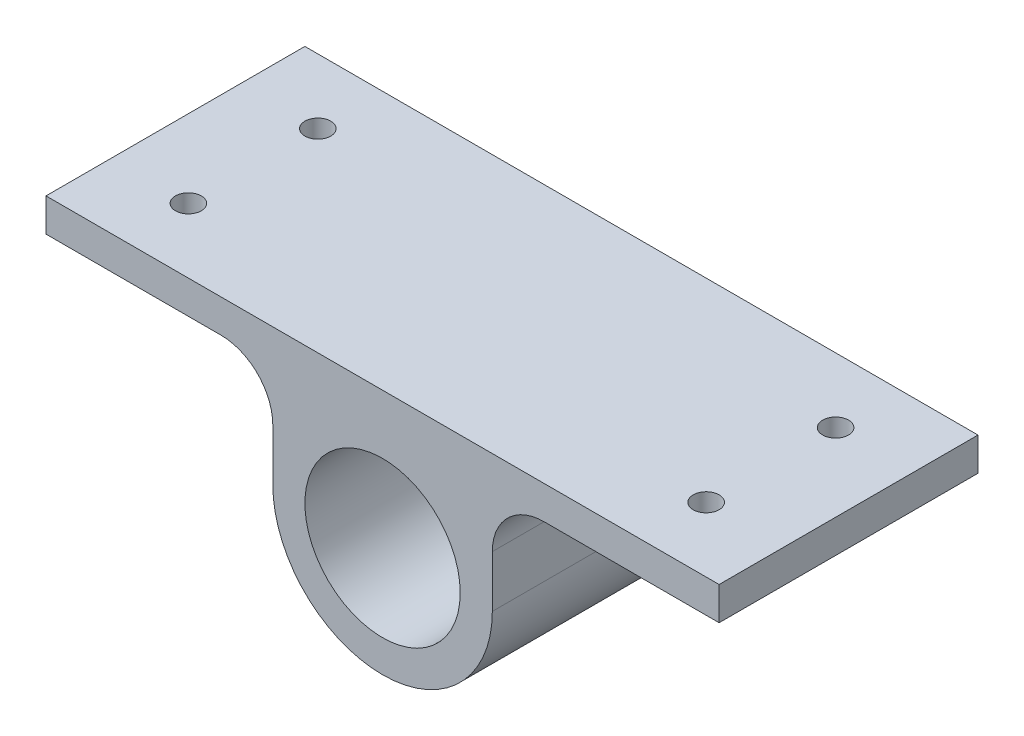
from build123d import *

# Parameters (mm, degrees)
BOSS_EXTRUDE1_DEPTH = 250
SKETCH2_R           = 75
CUT_EXTRUDE1_DEPTH  = 250
SKETCH3_R           = 12.5
CUT_EXTRUDE2_DEPTH  = 250


with BuildPart() as part:
    # Sketch1 → Boss-Extrude1 (new body)
    with BuildSketch(Plane.XY):
        with BuildLine():
            Line((-325, 132), (325, 132))
            Line((325, 132), (325, 100))
            Line((325, 100), (156, 100))
            ThreePointArc((156, 100), (120.644660941, 85.355339059), (106, 50))
            Line((106, 50), (106, 0))
            ThreePointArc((106, 0), (0, -106), (-106, 0))
            Line((-106, 0), (-106, 50))
            ThreePointArc((-106, 50), (-120.644660941, 85.355339059), (-156, 100))
            Line((-156, 100), (-325, 100))
            Line((-325, 100), (-325, 132))
        make_face()
    extrude(amount=BOSS_EXTRUDE1_DEPTH)

    # Sketch2 → Cut-Extrude1 (cut)
    with BuildSketch(Plane.XY.offset(250)):
        Circle(SKETCH2_R)
    extrude(amount=-CUT_EXTRUDE1_DEPTH, mode=Mode.SUBTRACT)

    # Sketch3 → Cut-Extrude2 (cut)
    with BuildSketch(Plane(origin=(0, 132, 0), x_dir=(1, 0, 0), z_dir=(0, 1, 0))):
        with Locations((-250, -62.5)):
            Circle(SKETCH3_R)
        with Locations((-250, -187.5)):
            Circle(SKETCH3_R)
        with Locations((250, -187.5)):
            Circle(SKETCH3_R)
        with Locations((250, -62.5)):
            Circle(SKETCH3_R)
    extrude(amount=-CUT_EXTRUDE2_DEPTH, mode=Mode.SUBTRACT)


solid = part.part
